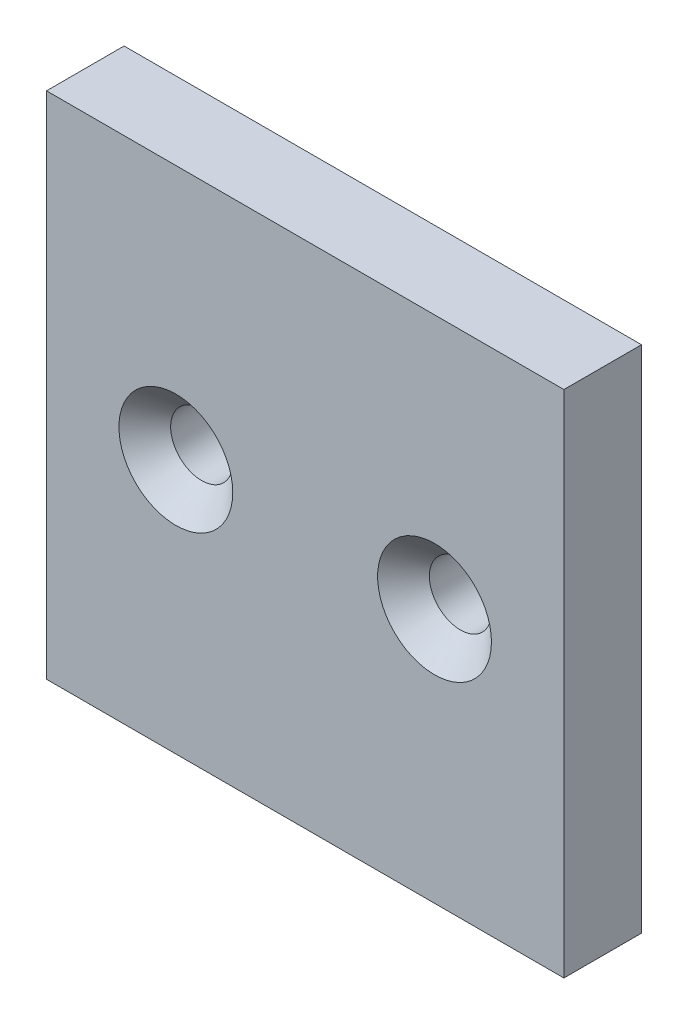
from build123d import *

# Parameters (mm, degrees)
SCHIZZO1_W                             = 20
SCHIZZO1_H                             = 19.7
ESTRUSIONE_ESTRUSIONE1_DEPTH           = 3
FORO_SVASATO_PER_VITE_M2_2_D           = 2.4
FORO_SVASATO_PER_VITE_M2_2_CSINK_D     = 4.4
FORO_SVASATO_PER_VITE_M2_2_CSINK_ANGLE = 90


with BuildPart() as part:
    # Schizzo1 → Estrusione-Estrusione1 (new body)
    with BuildSketch(Plane.XY):
        with Locations((10, 9.85)):
            Rectangle(SCHIZZO1_W, SCHIZZO1_H)
    extrude(amount=ESTRUSIONE_ESTRUSIONE1_DEPTH)

    # Foro svasato per Vite M2-2 (through all)
    with Locations(Plane.XY.offset(3)):
        with Locations((5, 9.85), (15, 9.85)):
            CounterSinkHole(FORO_SVASATO_PER_VITE_M2_2_D / 2, FORO_SVASATO_PER_VITE_M2_2_CSINK_D / 2, counter_sink_angle=FORO_SVASATO_PER_VITE_M2_2_CSINK_ANGLE)


solid = part.part
